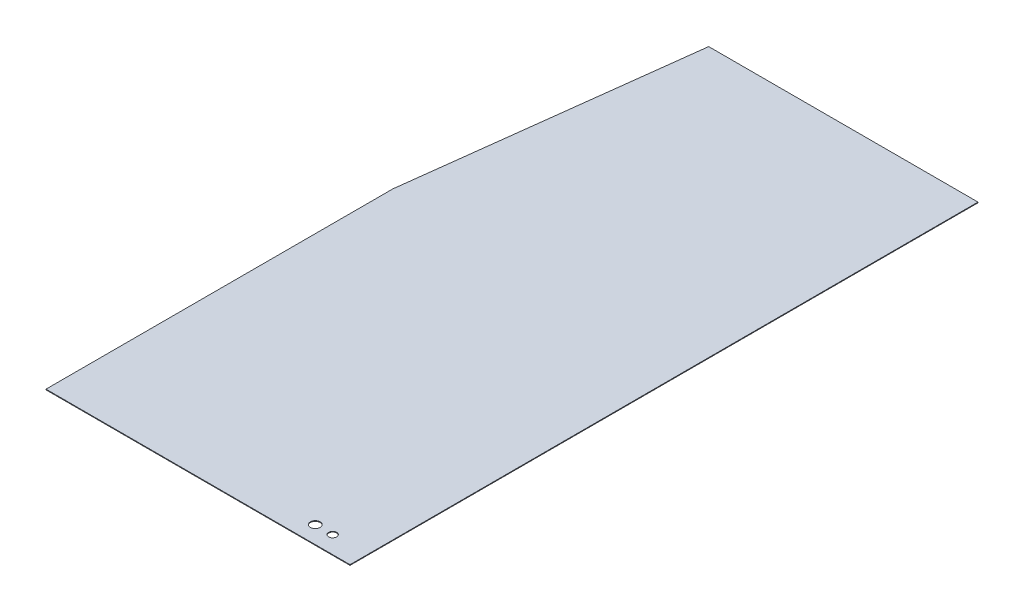
from build123d import *

# Parameters (mm, degrees)
SALIENTE_EXTRUIR1_DEPTH    = 1.9
CROQUIS3_R                 = 11.5
CROQUIS3_R_2               = 14
CORTAR_EXTRUIR1_DEPTH      = 1
CORTAR_EXTRUIR1_DEPTH_BACK = 2.9


with BuildPart() as part:
    # Croquis2 → Saliente-Extruir1 (new body)
    with BuildSketch(Plane(origin=(0, 0, 0), x_dir=(1, 0, 0), z_dir=(0, 1, 0))):
        Polygon((438.1, 0), (-438.1, 0), (-438.1, 1000), (-338.1, 1810), (438.1, 1810), align=None)
    extrude(amount=SALIENTE_EXTRUIR1_DEPTH)

    # Croquis3 → Cortar-Extruir1 (cut, two sides)
    with BuildSketch(Plane(origin=(0, 1.9, 0), x_dir=(1, 0, 0), z_dir=(0, 1, 0))) as cortar_extruir1_sk:
        with Locations((338.1, 50)):
            Circle(CROQUIS3_R)
        with Locations((288.1, 50)):
            Circle(CROQUIS3_R_2)
    extrude(amount=CORTAR_EXTRUIR1_DEPTH, mode=Mode.SUBTRACT)
    extrude(cortar_extruir1_sk.sketch, amount=-CORTAR_EXTRUIR1_DEPTH_BACK, mode=Mode.SUBTRACT)


solid = part.part
